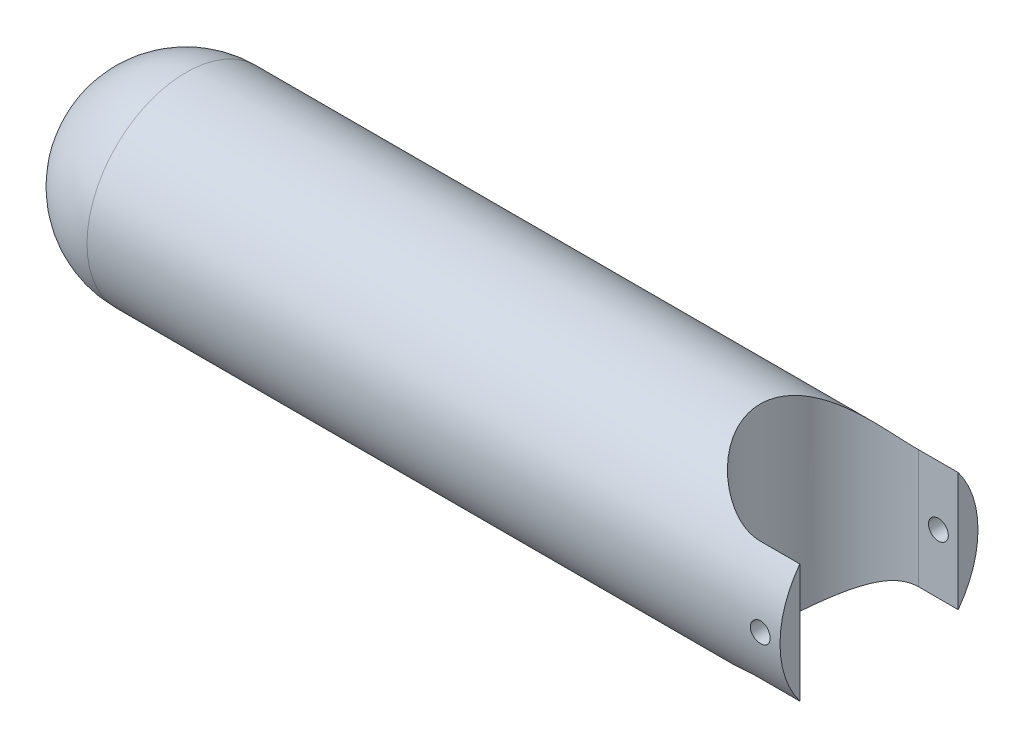
from build123d import *

# Parameters (mm, degrees)
CROQUIS6_R                 = 2.5
CORTAR_EXTRUIR1_DEPTH      = 26
CORTAR_EXTRUIR1_DEPTH_BACK = 26
CORTAR_EXTRUIR3_DEPTH      = 26.0000001
CORTAR_EXTRUIR3_DEPTH_BACK = 26.0000001


with BuildPart() as part:
    # Croquis3 → Revolución10 (revolve)
    with BuildSketch(Plane(origin=(0, 0, 0), x_dir=(1, 0, 0), z_dir=(0, 1, 0))):
        with BuildLine():
            Line((-38.081992127, 0), (161.918007873, 0))
            Line((161.918007873, 0), (161.918007873, 25))
            Line((161.918007873, 25), (-13.081992127, 25))
            ThreePointArc((-13.081992127, 25), (-30.759661656, 17.67766953), (-38.081992127, 0))
        make_face()
    revolve(axis=Axis((-38.081992127, 0, 0), (1, 0, 0)))

    # Croquis6 → Cortar-Extruir1 (cut, two sides)
    with BuildSketch(Plane.XY) as cortar_extruir1_sk:
        with Locations((156.918007873, 0)):
            Circle(CROQUIS6_R)
    extrude(amount=CORTAR_EXTRUIR1_DEPTH, mode=Mode.SUBTRACT)
    extrude(cortar_extruir1_sk.sketch, amount=-CORTAR_EXTRUIR1_DEPTH_BACK, mode=Mode.SUBTRACT)

    # Croquis9 → Cortar-Extruir3 (cut, two sides)
    with BuildSketch(Plane(origin=(0, 0, 0), x_dir=(1, 0, 0), z_dir=(0, 1, 0))) as cortar_extruir3_sk:
        with BuildLine():
            Line((161.918007873, 20), (161.918007873, -20))
            Line((161.918007873, -20), (151.918007873, -20))
            ThreePointArc((151.918007873, -20), (131.918007873, 0), (151.918007873, 20))
            Line((151.918007873, 20), (161.918007873, 20))
        make_face()
    extrude(amount=CORTAR_EXTRUIR3_DEPTH, mode=Mode.SUBTRACT)
    extrude(cortar_extruir3_sk.sketch, amount=-CORTAR_EXTRUIR3_DEPTH_BACK, mode=Mode.SUBTRACT)


solid = part.part
